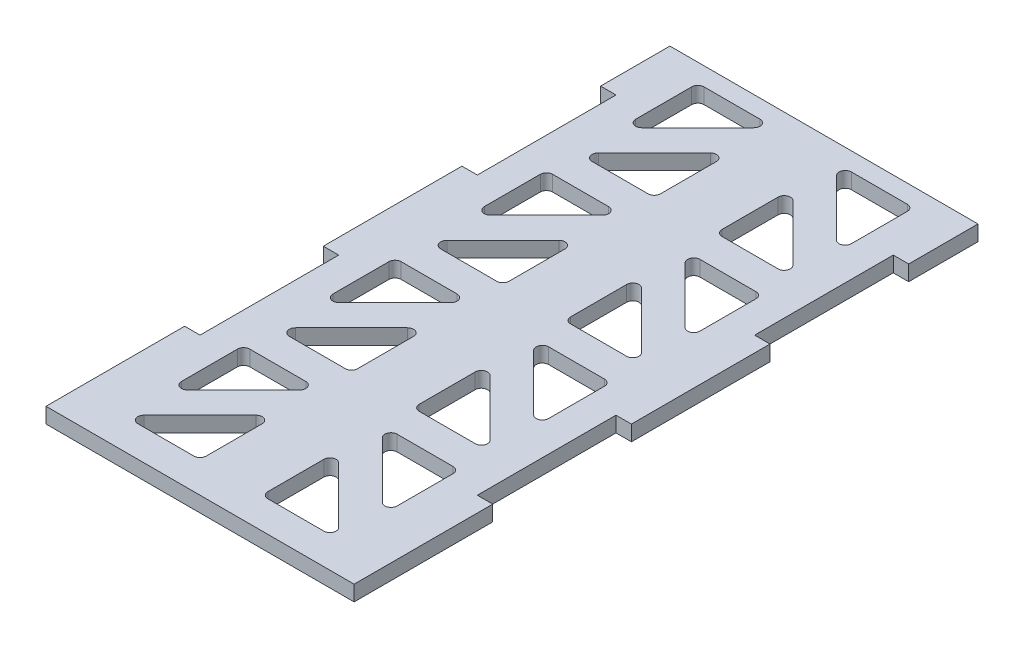
from build123d import *

# Parameters (mm, degrees)
BOSS_EXTRUDE1_DEPTH  = 3.175
CUT_EXTRUDE1_DEPTH   = 4.175
FILLET1_R            = 1.27
FILLET1_OF_MIRROR1_R = 1.27


with BuildPart() as part:
    # Sketch1 → Boss-Extrude1 (new body)
    with BuildSketch(Plane(origin=(0, -9.743731804, 0), x_dir=(1, 0, 0), z_dir=(0, 1, 0))):
        Polygon((28.575, 57.450862399), (28.575, 28.875862399), (31.75, 28.875862399), (31.75, 0.300862399), (28.575, 0.300862399), (28.575, -28.274137601), (31.75, -28.274137601), (31.75, -56.849137601), (-31.75, -56.849137601), (-31.75, -28.274137601), (-28.575, -28.274137601), (-28.575, 0.300862399), (-31.75, 0.300862399), (-31.75, 28.875862399), (-28.575, 28.875862399), (-28.575, 57.450862399), (-31.75, 57.450862399), (-31.75, 71.738362399), (31.75, 71.738362399), (31.75, 57.450862399), align=None)
    extrude(amount=BOSS_EXTRUDE1_DEPTH)

    # Sketch2 → Cut-Extrude1 (cut, through all)
    with BuildSketch(Plane(origin=(0, -6.568731804, 0), x_dir=(1, 0, 0), z_dir=(0, 1, 0))):
        Polygon((-22.225, -50.499137601), (-6.35, -50.499137601), (-6.35, -34.624137601), align=None)
        Polygon((-22.225, -41.51888148), (-6.35, -25.64388148), (-22.225, -25.64388148), align=None)
        Polygon((-6.35, -3.41888148), (-22.225, -19.29388148), (-6.35, -19.29388148), align=None)
        Polygon((-22.225, 5.561374641), (-22.225, -10.313625359), (-6.35, 5.561374641), align=None)
        Polygon((-6.35, 27.786374641), (-22.225, 11.911374641), (-6.35, 11.911374641), align=None)
        Polygon((-22.225, 36.766630762), (-22.225, 20.891630762), (-6.35, 36.766630762), align=None)
        Polygon((-6.35, 58.991630762), (-22.225, 43.116630762), (-6.35, 43.116630762), align=None)
        Polygon((-22.225, 67.971886883), (-22.225, 52.096886883), (-6.35, 67.971886883), align=None)
    cut_extrude1 = extrude(amount=-CUT_EXTRUDE1_DEPTH, mode=Mode.SUBTRACT)

    # Fillet1
    fillet1_edges = [part.edges().sort_by_distance(p)[0] for p in [
        (-22.225, -8.156231804, 41.51888148),
        (-22.225, -8.156231804, 25.64388148),
        (-6.35, -8.156231804, 25.64388148),
        (-6.35, -8.156231804, -67.971886883),
        (-22.225, -8.156231804, -52.096886883),
        (-22.225, -8.156231804, -67.971886883),
        (-6.35, -8.156231804, -43.116630762),
        (-22.225, -8.156231804, -43.116630762),
        (-6.35, -8.156231804, -58.991630762),
        (-6.35, -8.156231804, -36.766630762),
        (-22.225, -8.156231804, -20.891630762),
        (-22.225, -8.156231804, -36.766630762),
        (-22.225, -8.156231804, 50.499137601),
        (-6.35, -8.156231804, 34.624137601),
        (-6.35, -8.156231804, 50.499137601),
        (-6.35, -8.156231804, -11.911374641),
        (-22.225, -8.156231804, -11.911374641),
        (-6.35, -8.156231804, -27.786374641),
        (-6.35, -8.156231804, -5.561374641),
        (-22.225, -8.156231804, 10.313625359),
        (-22.225, -8.156231804, -5.561374641),
        (-6.35, -8.156231804, 19.29388148),
        (-22.225, -8.156231804, 19.29388148),
        (-6.35, -8.156231804, 3.41888148),
    ]]
    fillet(fillet1_edges, radius=FILLET1_R)

    # Mirror1: Cut-Extrude1 across plane
    add(cut_extrude1.mirror(Plane(origin=(0, 0, 0), x_dir=(0, 0, 1), z_dir=(1, 0, 0))), mode=Mode.SUBTRACT)

    # Fillet1 of Mirror1
    fillet1_of_mirror1_edges = [part.edges().sort_by_distance(p)[0] for p in [
        (22.225, -8.156231804, 41.51888148),
        (22.225, -8.156231804, 25.64388148),
        (6.35, -8.156231804, 25.64388148),
        (6.35, -8.156231804, -67.971886883),
        (22.225, -8.156231804, -52.096886883),
        (22.225, -8.156231804, -67.971886883),
        (6.35, -8.156231804, -43.116630762),
        (22.225, -8.156231804, -43.116630762),
        (6.35, -8.156231804, -58.991630762),
        (6.35, -8.156231804, -36.766630762),
        (22.225, -8.156231804, -20.891630762),
        (22.225, -8.156231804, -36.766630762),
        (22.225, -8.156231804, 50.499137601),
        (6.35, -8.156231804, 34.624137601),
        (6.35, -8.156231804, 50.499137601),
        (6.35, -8.156231804, -11.911374641),
        (22.225, -8.156231804, -11.911374641),
        (6.35, -8.156231804, -27.786374641),
        (6.35, -8.156231804, -5.561374641),
        (22.225, -8.156231804, 10.313625359),
        (22.225, -8.156231804, -5.561374641),
        (6.35, -8.156231804, 19.29388148),
        (22.225, -8.156231804, 19.29388148),
        (6.35, -8.156231804, 3.41888148),
    ]]
    fillet(fillet1_of_mirror1_edges, radius=FILLET1_OF_MIRROR1_R)


solid = part.part
